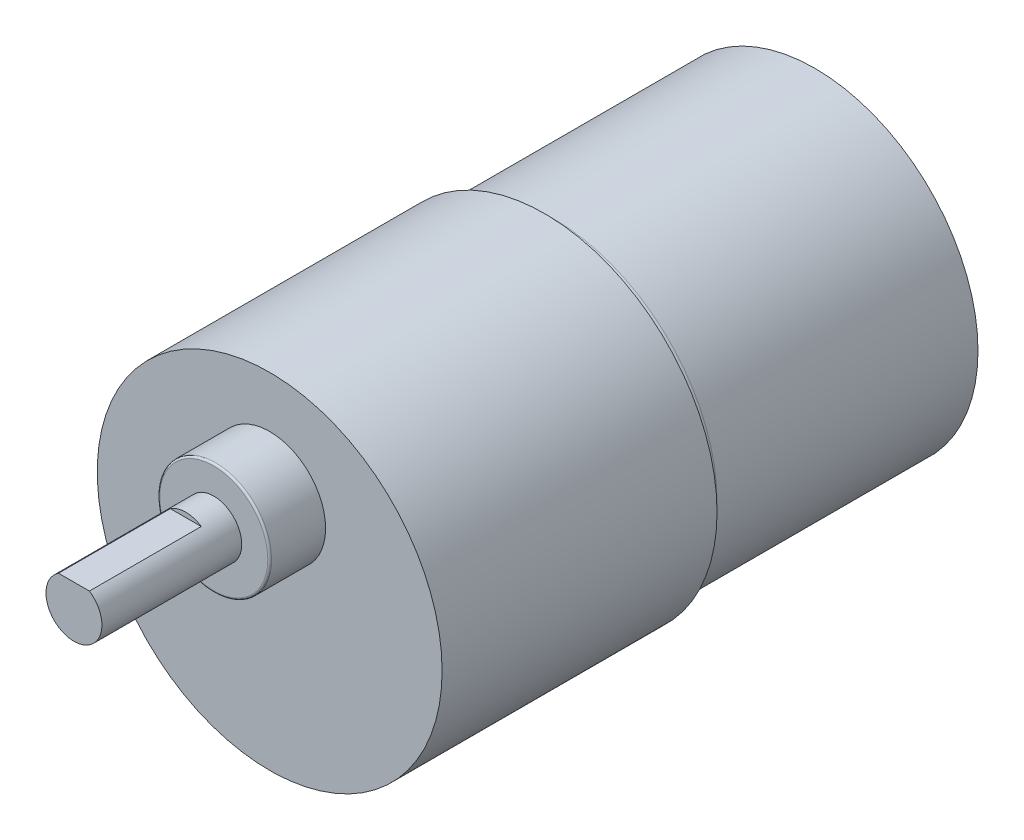
from build123d import *

# Parameters (mm, degrees)
SKETCH2_R           = 17.5
BOSS_EXTRUDE2_DEPTH = 29
FILLET2_R           = 1
SKETCH3_R           = 18.5
BOSS_EXTRUDE3_DEPTH = 29.5
SKETCH4_R           = 6
BOSS_EXTRUDE4_DEPTH = 6
FILLET6_R           = 0.2
SKETCH5_R           = 3
BOSS_EXTRUDE5_DEPTH = 3
BOSS_EXTRUDE6_DEPTH = 12


with BuildPart() as part:
    # Sketch2 → Boss-Extrude2 (new body)
    with BuildSketch(Plane.XY):
        Circle(SKETCH2_R)
    extrude(amount=BOSS_EXTRUDE2_DEPTH)

    # Fillet2
    fillet2_edges = [part.edges().sort_by_distance(p)[0] for p in [
        (-17.5, 0, 29),
    ]]
    fillet(fillet2_edges, radius=FILLET2_R)

    # Sketch3 → Boss-Extrude3 (add)
    with BuildSketch(Plane.XY.offset(29)):
        Circle(SKETCH3_R)
    extrude(amount=BOSS_EXTRUDE3_DEPTH)

    # Sketch4 → Boss-Extrude4 (add)
    with BuildSketch(Plane.XY.offset(58.5)):
        with Locations((0, 7)):
            Circle(SKETCH4_R)
    extrude(amount=BOSS_EXTRUDE4_DEPTH)

    # Fillet6
    fillet6_edges = [part.edges().sort_by_distance(p)[0] for p in [
        (-6, 7, 64.5),
    ]]
    fillet(fillet6_edges, radius=FILLET6_R)

    # Sketch5 → Boss-Extrude5 (add)
    with BuildSketch(Plane.XY.offset(64.5)):
        with Locations((0, 7)):
            Circle(SKETCH5_R)
    extrude(amount=BOSS_EXTRUDE5_DEPTH)

    # Sketch6 → Boss-Extrude6 (add)
    with BuildSketch(Plane.XY.offset(67.5)):
        with BuildLine():
            Line((-1.658312395, 9.5), (1.658312395, 9.5))
            ThreePointArc((1.658312395, 9.5), (0, 4), (-1.658312395, 9.5))
        make_face()
    extrude(amount=BOSS_EXTRUDE6_DEPTH)


solid = part.part
